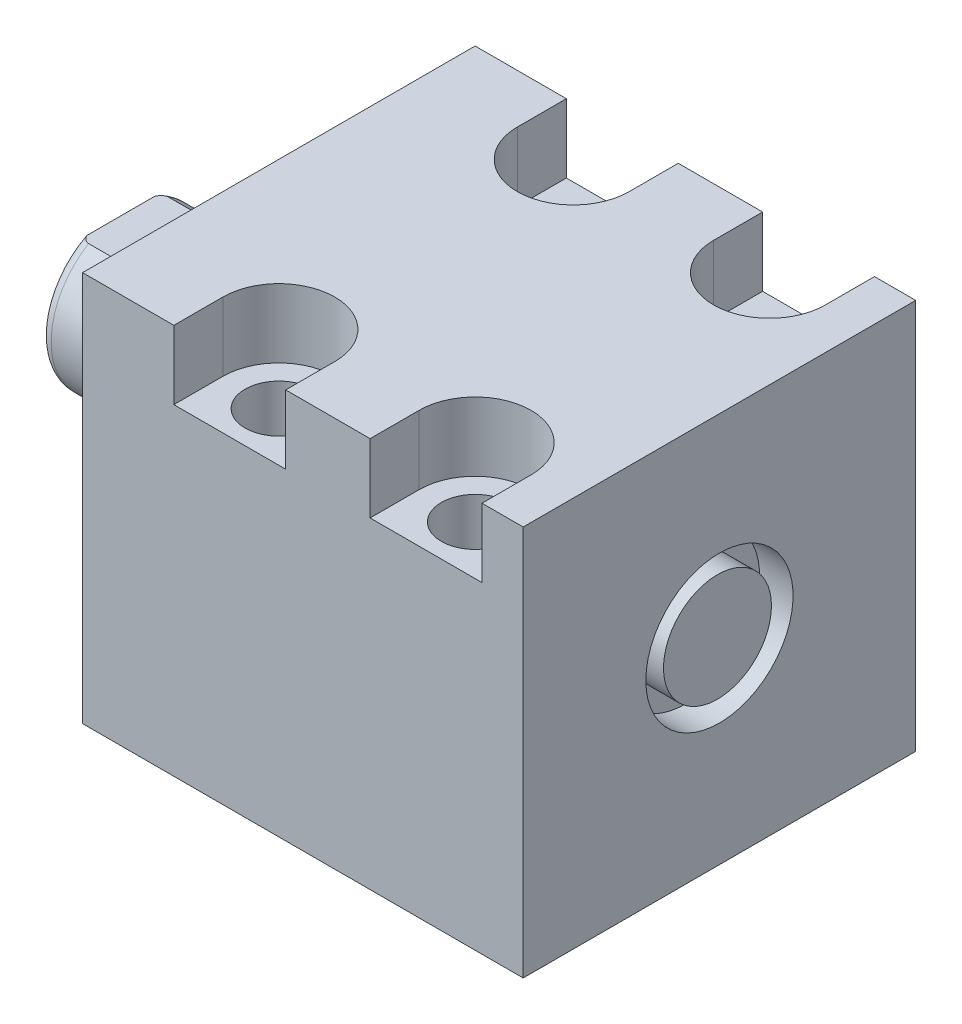
from build123d import *

# Parameters (mm, degrees)
SKETCH1_W          = 50.8
SKETCH1_H          = 50.546
EXTRUDE1_DEPTH     = 57.02
SKETCH5_R          = 17.4625
EXTRUDE2_DEPTH     = 5.969
SKETCH6_W          = 10.31875
SKETCH6_H          = 14.481
CUT_EXTRUDE4_DEPTH = 30.48
HOLE2_D            = 8.7376
HOLE2_DEPTH        = 50.546
LPATTERN1_COUNT    = 2
LPATTERN1_PITCH    = 25.4
CUT_EXTRUDE5_DEPTH = 8.89
HOLE3_D            = 3.175
HOLE3_DEPTH        = 11.303
HOLE3_CBORE_D      = 11.3411
HOLE3_CBORE_DEPTH  = 1.4478
HOLE3_TIP          = 0.953866233
HOLE4_D            = 3.175
HOLE4_DEPTH        = 13.8684
HOLE4_CBORE_D      = 11.3411
HOLE4_CBORE_DEPTH  = 1.4478
HOLE4_TIP          = 0.953866233
CHAMFER1_SIZE      = 0.635
SKETCH23_R         = 1.4478
LPATTERN3_COUNT    = 2
LPATTERN3_PITCH    = 25.4
SKETCH24_W         = 4.318
SKETCH24_H         = 9.525
SKETCH25_R         = 6.985
EXTRUDE3_DEPTH     = 4.064


with BuildPart() as part:
    # Sketch1 → Extrude1 (new body)
    with BuildSketch(Plane(origin=(0, 0, 0), x_dir=(0, 0, -1), z_dir=(1, 0, 0))):
        with Locations((0, -0.127)):
            Rectangle(SKETCH1_W, SKETCH1_H)
    extrude(amount=EXTRUDE1_DEPTH)

    # Sketch5 → Extrude2 (add)
    with BuildSketch(Plane.ZY):
        with Locations(Location((0, 0, 0), (0, 0, 180))):  # turned: the seam where the file's is
            Circle(SKETCH5_R)
    extrude(amount=EXTRUDE2_DEPTH)

    # Sketch6 → Revolve1 (revolve)
    with BuildSketch(Plane(origin=(0, 0, 0), x_dir=(0, 0, 1), z_dir=(0, -1, 0))):
        with Locations((-5.159375, 13.2095)):
            Rectangle(SKETCH6_W, SKETCH6_H)
    revolve(axis=Axis((5.754582971, 0, 0), (-1, 0, 0)))

    # S2D0001 → Cut-Revolve4 (revolve, cut)
    with BuildSketch(Plane(origin=(-18.511260017, 3.2639, 0), x_dir=(0, 1, 0), z_dir=(0, 0, 1)), mode=Mode.PRIVATE) as cut_revolve4_sk:
        Polygon((0, 0.003), (0, -14.647460017), (-3.2639, -14.647460017), (-3.2639, 1.938739983), (1.1176, 1.938739983), align=None)
    revolve(cut_revolve4_sk.sketch.rotate(Axis((0, 0, 0), (-1, 0, 0)), 90), axis=Axis((0, 0, 0), (-1, 0, 0)), mode=Mode.SUBTRACT)  # turned: the seam where the file's is

    # Sketch8 → Cut-Revolve5 (revolve, cut)
    with BuildSketch(Plane(origin=(0, 0, 0), x_dir=(0, 0, -1), z_dir=(0, 1, 0)), mode=Mode.PRIVATE) as cut_revolve5_sk:
        with BuildLine():
            Line((-10.31875, 13.0332), (-10.033, 13.7952))
            Line((-10.033, 13.7952), (-10.033, 19.434))
            ThreePointArc((-10.033, 19.434), (-9.932678675, 19.977796865), (-9.644922533, 20.45))
            Line((-9.644922533, 20.45), (-10.31875, 20.45))
            Line((-10.31875, 20.45), (-10.31875, 13.0332))
        make_face()
    revolve(cut_revolve5_sk.sketch.rotate(Axis((-12.65936, 0, 0), (-1, 0, 0)), 180), axis=Axis((-12.65936, 0, 0), (-1, 0, 0)), mode=Mode.SUBTRACT)  # turned: the seam where the file's is

    # Sketch12 → Cut-Extrude4 (cut, symmetric)
    with BuildSketch(Plane(origin=(0, 0, 0), x_dir=(0, -1, 0), z_dir=(0, 0, -1))):
        Polygon((8.5852, 20.45), (8.5852, 15.497), (10.033, 14.0492), (10.033, 20.45), align=None)
        Polygon((-8.5852, 20.45), (-8.5852, 15.497), (-10.033, 14.0492), (-10.033, 20.45), align=None)
    extrude(amount=CUT_EXTRUDE4_DEPTH, both=True, mode=Mode.SUBTRACT)

    # Hole2
    with Locations(Plane(origin=(0, 25.146, 0), x_dir=(-1, 0, 0), z_dir=(0, 1, 0))):
        with Locations((-19.05, -19.05), (-19.05, 19.05)):
            hole2 = Hole(HOLE2_D / 2, depth=HOLE2_DEPTH)

    # LPattern1: Hole2 ×2
    with Locations(*[(i * LPATTERN1_PITCH, 0, 0) for i in range(1, LPATTERN1_COUNT)]):
        add(hole2, mode=Mode.SUBTRACT)

    # Sketch18 → Cut-Extrude5 (cut)
    with BuildSketch(Plane(origin=(0, 25.146, 0), x_dir=(1, 0, 0), z_dir=(0, 1, 0))):
        with BuildLine():
            Line((51.689, -25.4), (37.211, -25.4))
            Line((37.211, -25.4), (37.211, -19.05))
            ThreePointArc((37.211, -19.05), (44.45, -11.811), (51.689, -19.05))
            Line((51.689, -19.05), (51.689, -25.4))
        make_face()
        with BuildLine():
            Line((11.811, -19.05), (11.811, -25.4))
            Line((11.811, -25.4), (26.289, -25.4))
            Line((26.289, -25.4), (26.289, -19.05))
            ThreePointArc((26.289, -19.05), (19.05, -11.811), (11.811, -19.05))
        make_face()
        with BuildLine():
            Line((51.689, 19.05), (51.689, 25.4))
            Line((51.689, 25.4), (37.211, 25.4))
            Line((37.211, 25.4), (37.211, 19.05))
            ThreePointArc((37.211, 19.05), (44.45, 11.811), (51.689, 19.05))
        make_face()
        with BuildLine():
            Line((26.289, 25.4), (11.811, 25.4))
            Line((11.811, 25.4), (11.811, 19.05))
            ThreePointArc((11.811, 19.05), (19.05, 11.811), (26.289, 19.05))
            Line((26.289, 19.05), (26.289, 25.4))
        make_face()
    extrude(amount=-CUT_EXTRUDE5_DEPTH, mode=Mode.SUBTRACT)

    # Hole3
    with Locations(Plane.XZ.offset(25.4)):
        with Locations((12.7, 0)):
            CounterBoreHole(HOLE3_D / 2, HOLE3_CBORE_D / 2, HOLE3_CBORE_DEPTH, depth=HOLE3_DEPTH)
            with Locations((0, 0, -(HOLE3_DEPTH + HOLE3_TIP / 2))):  # 118° drill point
                Cone(0, HOLE3_D / 2, HOLE3_TIP, mode=Mode.SUBTRACT)

    # Hole4
    with Locations(Plane.XZ.offset(25.4)):
        with Locations((38.1, 0)):
            CounterBoreHole(HOLE4_D / 2, HOLE4_CBORE_D / 2, HOLE4_CBORE_DEPTH, depth=HOLE4_DEPTH)
            with Locations((0, 0, -(HOLE4_DEPTH + HOLE4_TIP / 2))):  # 118° drill point
                Cone(0, HOLE4_D / 2, HOLE4_TIP, mode=Mode.SUBTRACT)

    # Chamfer1
    chamfer1_edges = [part.edges().sort_by_distance(p)[0] for p in [
        (14.2875, -23.9522, 0),
        (39.6875, -23.9522, 0),
    ]]
    chamfer(chamfer1_edges, length=CHAMFER1_SIZE)

    # Sketch24 → Cut-Revolve6 (revolve, cut)
    with BuildSketch(Plane.XY, mode=Mode.PRIVATE) as cut_revolve6_sk:
        with Locations((54.861, 4.7625)):
            Rectangle(SKETCH24_W, SKETCH24_H)
    revolve(cut_revolve6_sk.sketch.rotate(Axis((0, 0, 0), (1, 0, 0)), 270), axis=Axis((0, 0, 0), (1, 0, 0)), mode=Mode.SUBTRACT)  # turned: the seam where the file's is

    # Sketch25 → Extrude3 (add)
    with BuildSketch(Plane(origin=(52.702, 0, 0), x_dir=(0, 0, -1), z_dir=(1, 0, 0))):
        Circle(SKETCH25_R)
    extrude(amount=EXTRUDE3_DEPTH)


with BuildPart() as body_2:
    # Sketch23 → Revolve2 (revolve)
    with BuildSketch(Plane.XY, mode=Mode.PRIVATE) as revolve2_sk:
        with Locations((8.47725, -25.4)):
            Circle(SKETCH23_R)
    revolve(revolve2_sk.sketch.rotate(Axis((12.7, -23.9522, 0), (0, 1, 0)), 270), axis=Axis((12.7, -23.9522, 0), (0, 1, 0)))  # turned: the seam where the file's is


with BuildPart() as lpattern3_1:
    # LPattern3: pattern copy
    add(body_2.part.moved(Location(Vector(1, 0, 0) * (1 * LPATTERN3_PITCH))))


solid = Compound([part.part, body_2.part, lpattern3_1.part])
